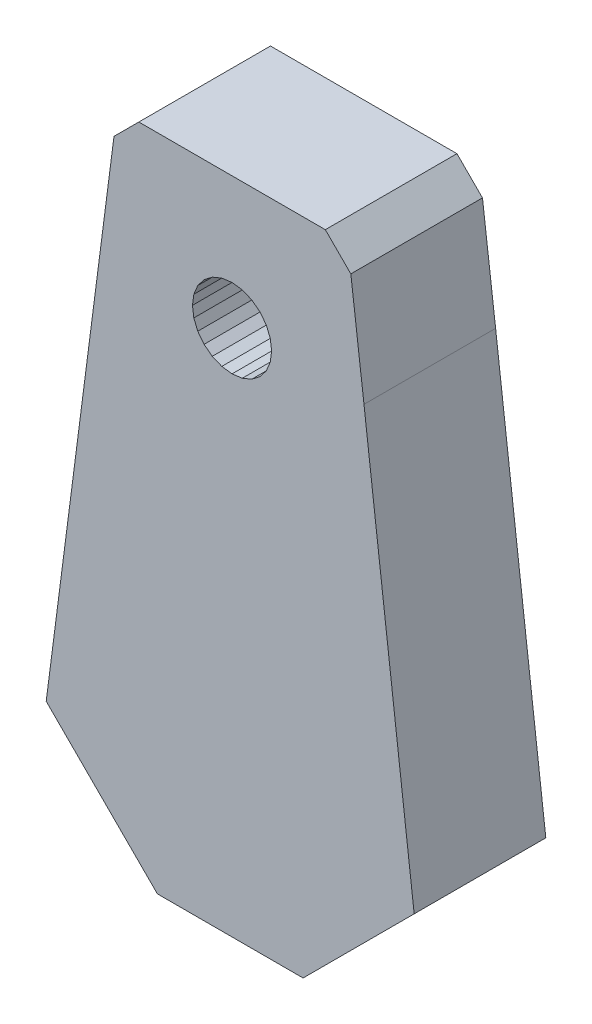
from build123d import *

# Parameters (mm, degrees)
BOSS_EXTRUDE1_DEPTH = 6


with BuildPart() as part:
    # Sketch1 → Boss-Extrude1 (new body)
    with BuildSketch(Plane.XY):
        Polygon((457.663031463, 187.980636569), (464.304980239, 187.980636569), (469.367845751, 193.043502081), (467.079834781, 212.013718005), (466.481000515, 216.863814529), (465.31762376, 218.027191284), (456.81762376, 218.027191284), (455.685560331, 216.895127855), (452.59487335, 193.048794682), align=None)
        Polygon((461.066361502, 210.209676022), (460.599441079, 210.271147261), (460.16434051, 210.451371818), (459.790711182, 210.738067685), (459.504015315, 211.111697013), (459.323790759, 211.546797582), (459.262319519, 212.013718005), (459.323790759, 212.480638429), (459.504015315, 212.915738997), (459.790711182, 213.289368326), (460.16434051, 213.576064193), (460.599441079, 213.756288749), (461.066361502, 213.817759989), (461.533281926, 213.756288749), (461.968382494, 213.576064193), (462.342011823, 213.289368326), (462.62870769, 212.915738997), (462.808932246, 212.480638429), (462.870403486, 212.013718005), (462.808932246, 211.546797582), (462.62870769, 211.111697013), (462.342011823, 210.738067685), (461.968382494, 210.451371818), (461.533281926, 210.271147261), align=None, mode=Mode.SUBTRACT)
    extrude(amount=BOSS_EXTRUDE1_DEPTH)


solid = part.part
